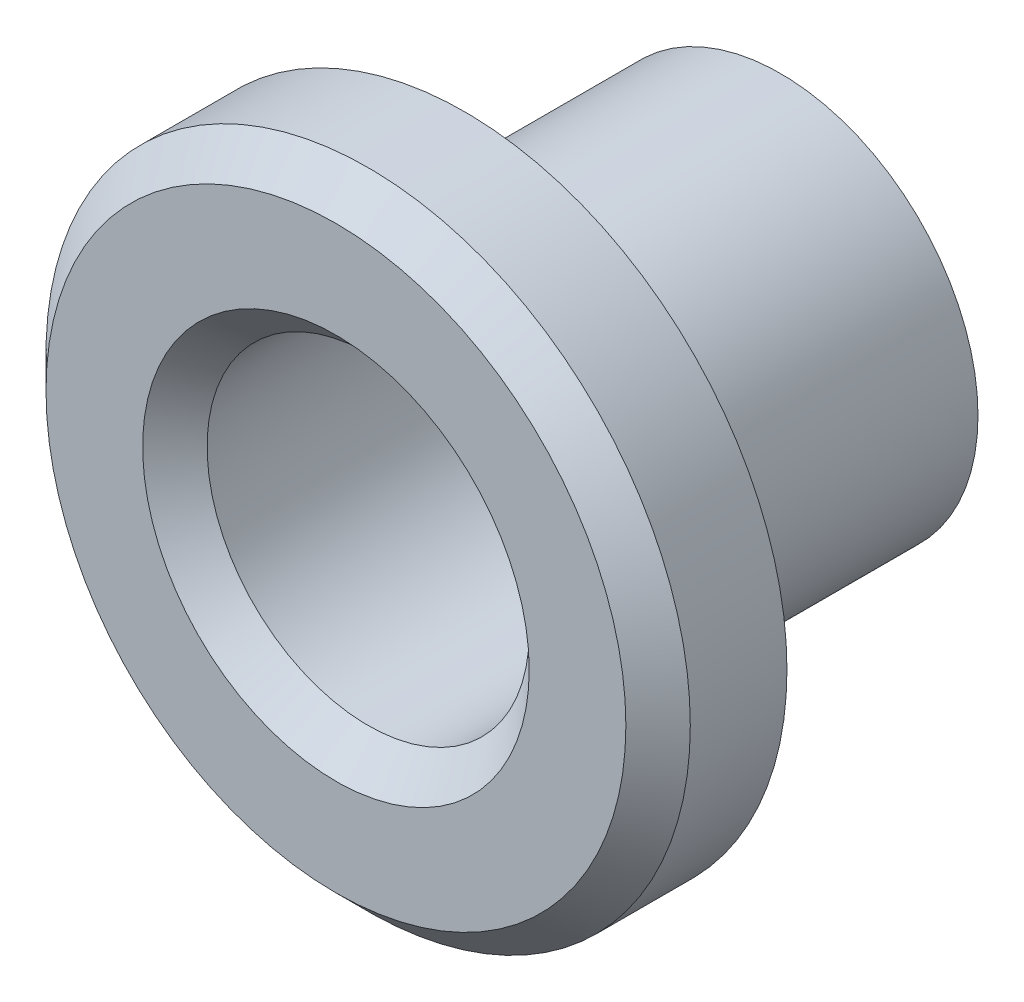
from build123d import *

# Parameters (mm, degrees)
SKETCH1_R           = 3.065
BOSS_EXTRUDE1_DEPTH = 4.9
SKETCH2_R           = 5
BOSS_EXTRUDE2_DEPTH = 2
SKETCH3_R           = 2.5
CUT_EXTRUDE1_DEPTH  = 7.9
CHAMFER1_SIZE       = 0.5
CHAMFER2_SIZE       = 0.5


with BuildPart() as part:
    # Sketch1 → Boss-Extrude1 (new body)
    with BuildSketch(Plane.XY):
        Circle(SKETCH1_R)
    extrude(amount=BOSS_EXTRUDE1_DEPTH)

    # Sketch2 → Boss-Extrude2 (add)
    with BuildSketch(Plane.XY.offset(4.9)):
        Circle(SKETCH2_R)
    extrude(amount=BOSS_EXTRUDE2_DEPTH)

    # Sketch3 → Cut-Extrude1 (cut, through all)
    with BuildSketch(Plane.XY.offset(6.9)):
        Circle(SKETCH3_R)
    extrude(amount=-CUT_EXTRUDE1_DEPTH, mode=Mode.SUBTRACT)

    # Chamfer1
    chamfer1_edges = [part.edges().sort_by_distance(p)[0] for p in [
        (-5, 0, 6.9),
    ]]
    chamfer(chamfer1_edges, length=CHAMFER1_SIZE)

    # Chamfer2
    chamfer2_edges = [part.edges().sort_by_distance(p)[0] for p in [
        (-2.5, 0, 6.9),
    ]]
    chamfer(chamfer2_edges, length=CHAMFER2_SIZE)


solid = part.part
